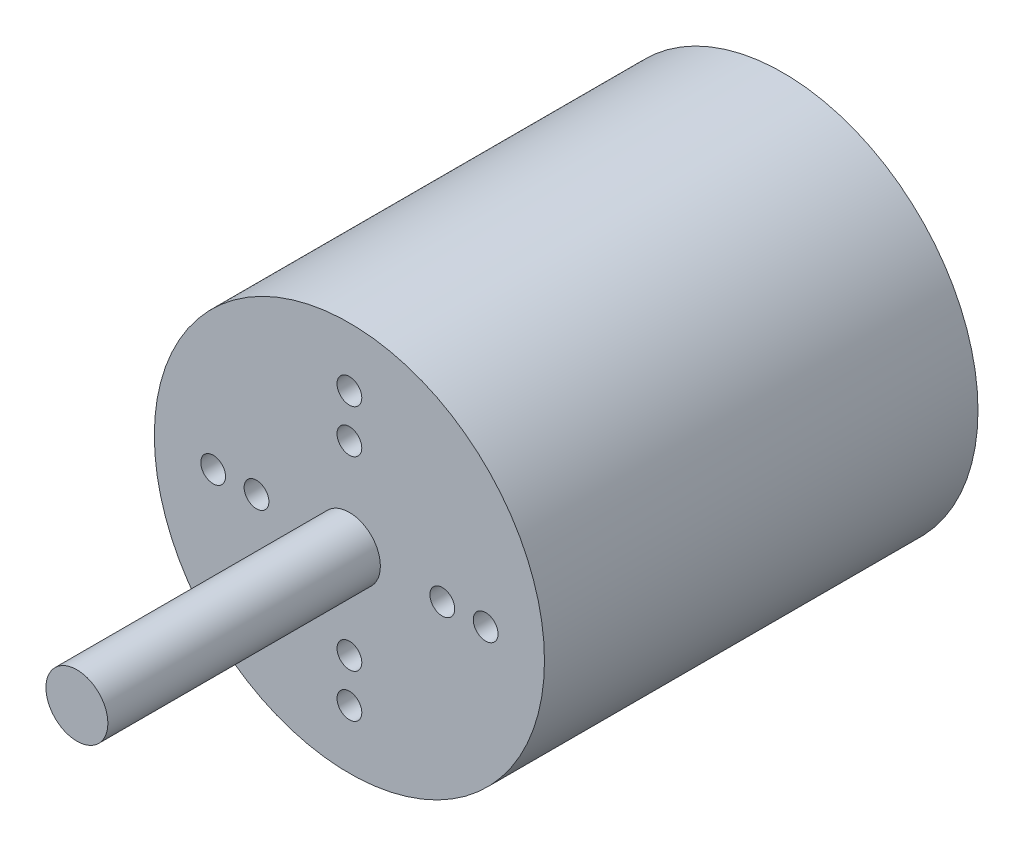
from build123d import *

# Parameters (mm, degrees)
SKETCH1_R           = 31.5
BOSS_EXTRUDE1_DEPTH = 70
SKETCH2_R           = 5
BOSS_EXTRUDE2_DEPTH = 44
SKETCH5_R           = 2
CUT_EXTRUDE2_DEPTH  = 10
SKETCH6_R           = 2
CUT_EXTRUDE3_DEPTH  = 5
CIRPATTERN1_COUNT   = 4
CIRPATTERN2_COUNT   = 4


with BuildPart() as part:
    # Sketch1 → Boss-Extrude1 (new body)
    with BuildSketch(Plane.XY):
        Circle(SKETCH1_R)
    extrude(amount=-BOSS_EXTRUDE1_DEPTH)

    # Sketch2 → Boss-Extrude2 (add)
    with BuildSketch(Plane.XY):
        Circle(SKETCH2_R)
    extrude(amount=BOSS_EXTRUDE2_DEPTH)

    # Sketch5 → Cut-Extrude2 (cut)
    with BuildSketch(Plane(origin=(0, 0, -70), x_dir=(-1, 0, 0), z_dir=(0, 0, -1))):
        with Locations((-11, 0)):
            Circle(SKETCH5_R)
    cut_extrude2 = extrude(amount=-CUT_EXTRUDE2_DEPTH, mode=Mode.SUBTRACT)

    # Sketch6 → Cut-Extrude3 (cut)
    with BuildSketch(Plane.XY):
        with Locations((0, 15)):
            Circle(SKETCH6_R)
        with Locations((0, 22)):
            Circle(SKETCH6_R)
    cut_extrude3 = extrude(amount=-CUT_EXTRUDE3_DEPTH, mode=Mode.SUBTRACT)

    # CirPattern1: Cut-Extrude3 ×4 about axis
    cirpattern1_axis = Axis((0, 0, 0), (0, 0, 1))
    for i in range(1, CIRPATTERN1_COUNT):
        add(cut_extrude3.rotate(cirpattern1_axis, i * 360 / CIRPATTERN1_COUNT), mode=Mode.SUBTRACT)

    # CirPattern2: Cut-Extrude2 ×4 about axis
    cirpattern2_axis = Axis((0, 0, 0), (0, 0, 1))
    for i in range(1, CIRPATTERN2_COUNT):
        add(cut_extrude2.rotate(cirpattern2_axis, i * 360 / CIRPATTERN2_COUNT), mode=Mode.SUBTRACT)


solid = part.part
